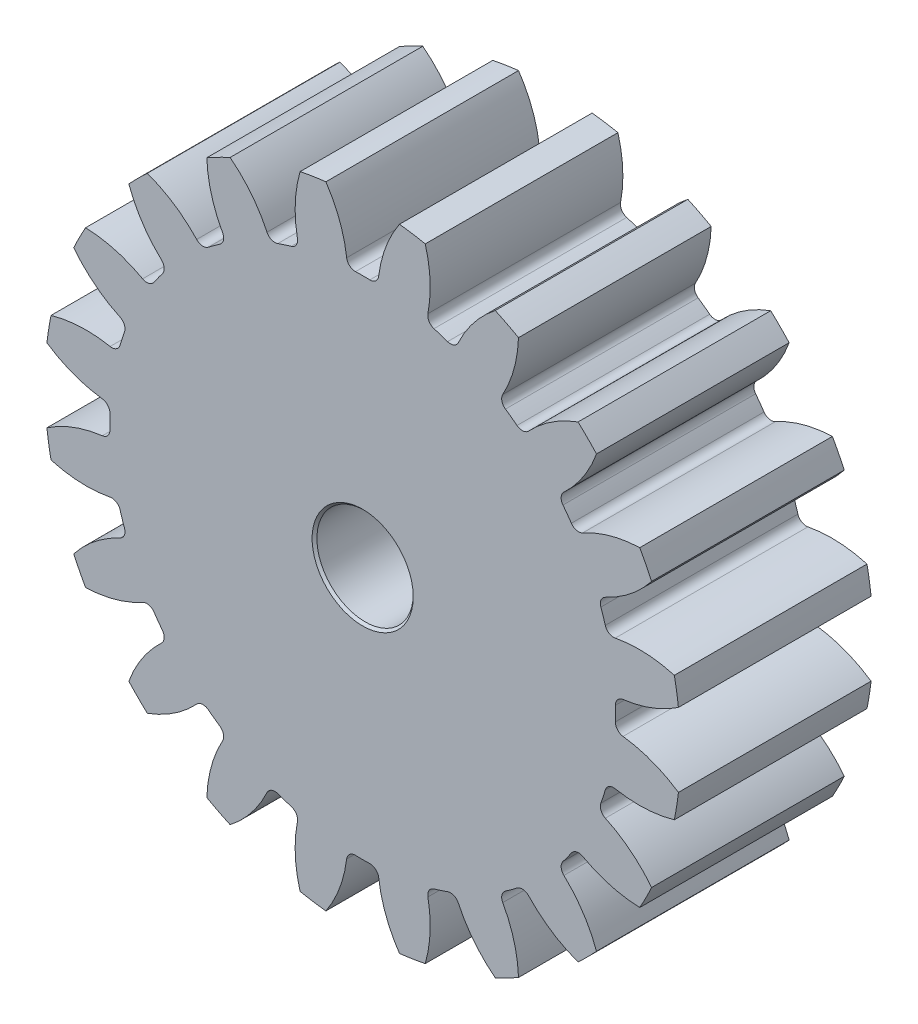
from build123d import *

# Parameters (mm, degrees)
SKETCH1_R                = 33
EXTRUDE2_DEPTH           = 10
EXTRUDE3_DEPTH           = 11
FILLET1_R                = 0.9
CIRPATTERN1_COUNT        = 20
FILLET1_OF_CIRPATTERN1_R = 0.9
SKETCH3_R                = 5
EXTRUDE4_DEPTH           = 1.0000001
EXTRUDE4_DEPTH_BACK      = 21.0000001
CHAMFER1_SIZE            = 0.25
SCALE1_SCALE             = 0.05


with BuildPart() as part:
    # Sketch1 → Extrude2 (new body, symmetric)
    with BuildSketch(Plane.XY):
        Circle(SKETCH1_R)
    extrude(amount=EXTRUDE2_DEPTH, both=True)

    # Sketch2 → Extrude3 (cut, symmetric)
    with BuildSketch(Plane.XY):
        with BuildLine():
            ThreePointArc((-4.503019526, 33.700486868), (-2.456350481, 30.179933833), (-1.584390569, 26.202141258))
            ThreePointArc((-1.584390569, 26.202141258), (0, 26.25), (1.584390569, 26.202141258))
            ThreePointArc((1.584390569, 26.202141258), (2.456350481, 30.179933833), (4.503019526, 33.700486868))
            ThreePointArc((4.503019526, 33.700486868), (0, 34), (-4.503019526, 33.700486868))
        make_face()
    extrude3 = extrude(amount=EXTRUDE3_DEPTH, both=True, mode=Mode.SUBTRACT)

    # Fillet1
    fillet1_edges = [part.edges().sort_by_distance(p)[0] for p in [
        (-1.584390569, 26.202141258, 0),
        (1.584390569, 26.202141258, 0),
    ]]
    fillet(fillet1_edges, radius=FILLET1_R)

    # CirPattern1: Extrude3 ×20 about axis
    cirpattern1_axis = Axis((0, 0, 0), (0, 0, 1))
    for i in range(1, CIRPATTERN1_COUNT):
        add(extrude3.rotate(cirpattern1_axis, i * 360 / CIRPATTERN1_COUNT), mode=Mode.SUBTRACT)

    # Fillet1 of CirPattern1
    fillet1_of_cirpattern1_edges = [part.edges().sort_by_distance(p)[0] for p in [
        (-9.603751913, 24.430113573, 0),
        (-6.590061963, 25.409320796, 0),
        (-16.683031106, 20.266696157, 0),
        (-14.119433314, 22.129258977, 0),
        (-22.129258977, 14.119433314, 0),
        (-20.266696157, 16.683031106, 0),
        (-25.409320796, 6.590061963, 0),
        (-24.430113573, 9.603751913, 0),
        (-26.202141258, -1.584390569, 0),
        (-26.202141258, 1.584390569, 0),
        (-24.430113573, -9.603751913, 0),
        (-25.409320796, -6.590061963, 0),
        (-20.266696157, -16.683031106, 0),
        (-22.129258977, -14.119433314, 0),
        (-14.119433314, -22.129258977, 0),
        (-16.683031106, -20.266696157, 0),
        (-6.590061963, -25.409320796, 0),
        (-9.603751913, -24.430113573, 0),
        (1.584390569, -26.202141258, 0),
        (-1.584390569, -26.202141258, 0),
        (9.603751913, -24.430113573, 0),
        (6.590061963, -25.409320796, 0),
        (16.683031106, -20.266696157, 0),
        (14.119433314, -22.129258977, 0),
        (22.129258977, -14.119433314, 0),
        (20.266696157, -16.683031106, 0),
        (25.409320796, -6.590061963, 0),
        (24.430113573, -9.603751913, 0),
        (26.202141258, 1.584390569, 0),
        (26.202141258, -1.584390569, 0),
        (24.430113573, 9.603751913, 0),
        (25.409320796, 6.590061963, 0),
        (20.266696157, 16.683031106, 0),
        (22.129258977, 14.119433314, 0),
        (14.119433314, 22.129258977, 0),
        (16.683031106, 20.266696157, 0),
        (6.590061963, 25.409320796, 0),
        (9.603751913, 24.430113573, 0),
    ]]
    fillet(fillet1_of_cirpattern1_edges, radius=FILLET1_OF_CIRPATTERN1_R)

    # Sketch3 → Extrude4 (cut, two sides)
    with BuildSketch(Plane.XY.offset(10)) as extrude4_sk:
        Circle(SKETCH3_R)
    extrude(amount=EXTRUDE4_DEPTH, mode=Mode.SUBTRACT)
    extrude(extrude4_sk.sketch, amount=-EXTRUDE4_DEPTH_BACK, mode=Mode.SUBTRACT)

    # Chamfer1
    chamfer1_edges = [part.edges().sort_by_distance(p)[0] for p in [
        (-5, 0, 10),
        (-5, 0, -10),
    ]]
    chamfer(chamfer1_edges, length=CHAMFER1_SIZE)


with BuildPart() as part_1:
    # Scale1: scaled about (0, 0, 0)
    add(part.part.scale(SCALE1_SCALE))


solid = part_1.part
